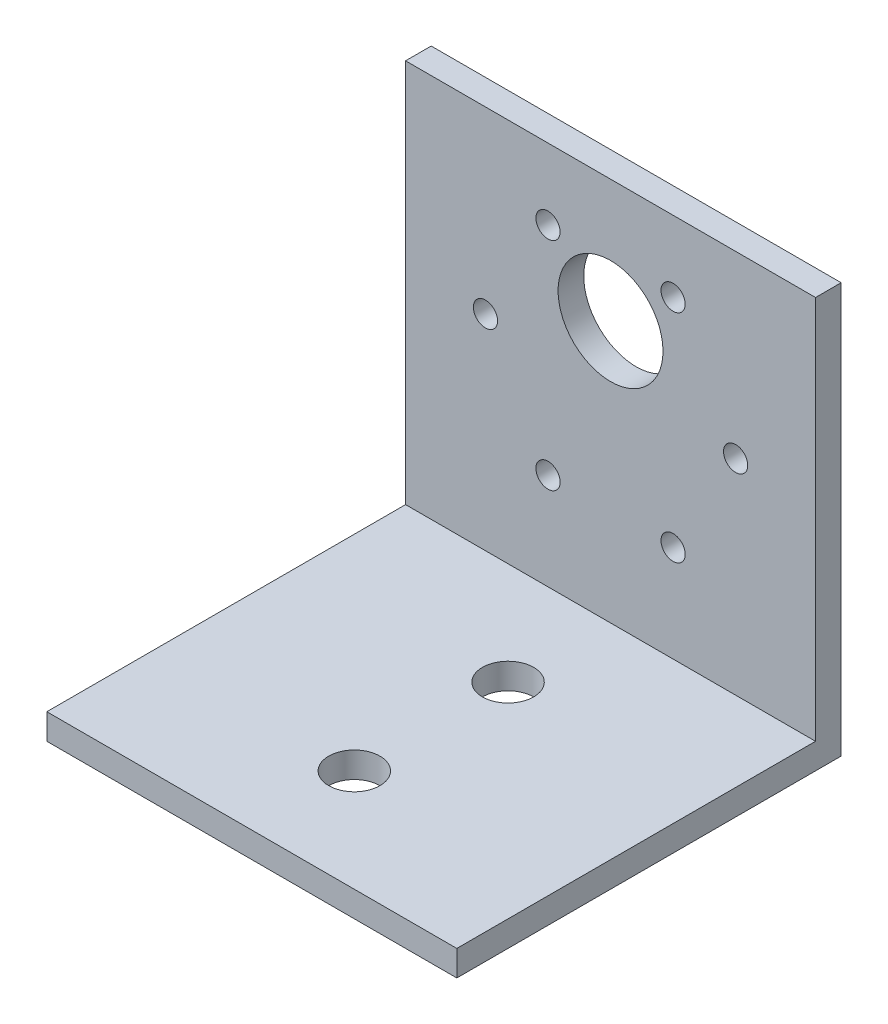
from build123d import *

# Parameters (mm, degrees)
SKETCH1_W           = 50.8
SKETCH1_H           = 50.8
SKETCH1_R           = 6.5
SKETCH1_R_2         = 1.5
BOSS_EXTRUDE1_DEPTH = 3.175
SKETCH2_W           = 50.8
SKETCH2_H           = 3.175
BOSS_EXTRUDE2_DEPTH = 44.45
SKETCH3_R           = 3.175
CUT_EXTRUDE1_DEPTH  = 4.175


with BuildPart() as part:
    # Sketch1 → Boss-Extrude1 (new body)
    with BuildSketch(Plane.XY):
        with Locations((25.4, 25.4)):
            Rectangle(SKETCH1_W, SKETCH1_H)
        with Locations((25.4, 35.575)):
            Circle(SKETCH1_R, mode=Mode.SUBTRACT)
        with Locations((9.9, 28.575)):
            Circle(SKETCH1_R_2, mode=Mode.SUBTRACT)
        with Locations((40.9, 28.575)):
            Circle(SKETCH1_R_2, mode=Mode.SUBTRACT)
        with Locations((33.15, 15.151606241)):
            Circle(SKETCH1_R_2, mode=Mode.SUBTRACT)
        with Locations((17.65, 15.151606241)):
            Circle(SKETCH1_R_2, mode=Mode.SUBTRACT)
        with Locations((17.65, 41.998393759)):
            Circle(SKETCH1_R_2, mode=Mode.SUBTRACT)
        with Locations((33.15, 41.998393759)):
            Circle(SKETCH1_R_2, mode=Mode.SUBTRACT)
    extrude(amount=BOSS_EXTRUDE1_DEPTH)

    # Sketch2 → Boss-Extrude2 (add)
    with BuildSketch(Plane.XY.offset(3.175)):
        with Locations((25.4, 1.5875)):
            Rectangle(SKETCH2_W, SKETCH2_H)
    extrude(amount=BOSS_EXTRUDE2_DEPTH)

    # Sketch3 → Cut-Extrude1 (cut, through all)
    with BuildSketch(Plane(origin=(0, 3.175, 0), x_dir=(1, 0, 0), z_dir=(0, 1, 0))):
        with Locations((25.4, -15.875)):
            Circle(SKETCH3_R)
        with Locations((25.4, -34.925)):
            Circle(SKETCH3_R)
    extrude(amount=-CUT_EXTRUDE1_DEPTH, mode=Mode.SUBTRACT)


solid = part.part
